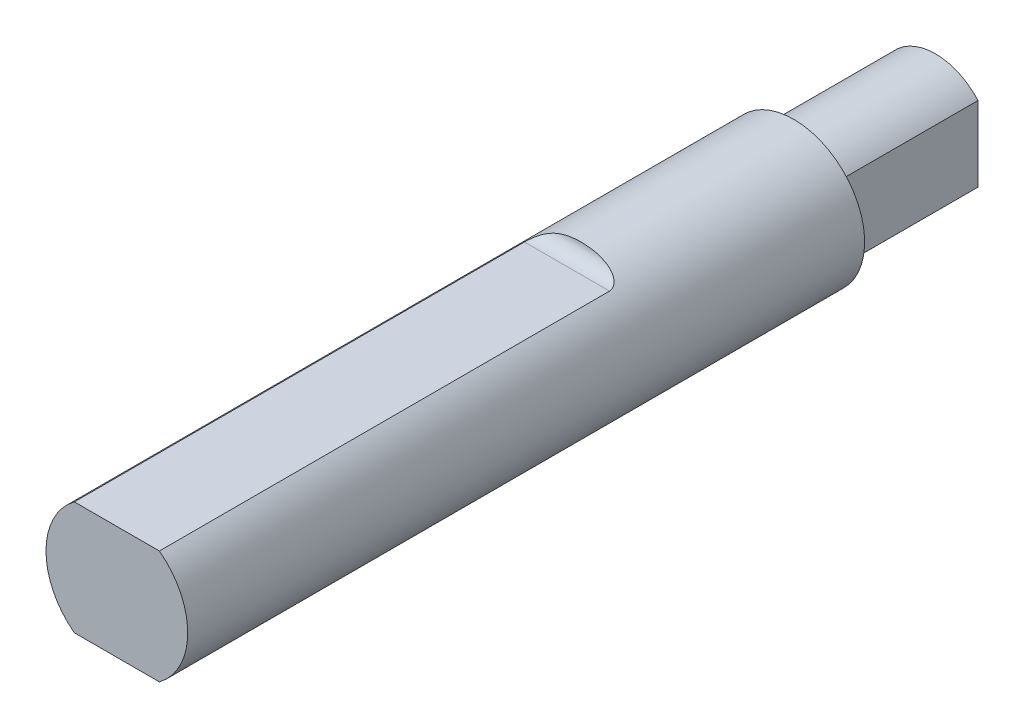
from build123d import *

# Parameters (mm, degrees)
SKETCH1_R               = 2.5
BOSS_EXTRUDE1_DEPTH     = 28.879
SKETCH2_R               = 2.5
CUT_EXTRUDE1_DEPTH      = 5
CUT_EXTRUDE2_DEPTH      = 15.879
CUT_EXTRUDE3_DEPTH      = 3.5
CUT_EXTRUDE3_DEPTH_BACK = 3.5


with BuildPart() as part:
    # Sketch1 → Boss-Extrude1 (new body)
    with BuildSketch(Plane.XY):
        Circle(SKETCH1_R)
    extrude(amount=BOSS_EXTRUDE1_DEPTH)

    # Sketch2 → Cut-Extrude1 (cut)
    with BuildSketch(Plane(origin=(0, 0, 0), x_dir=(-1, 0, 0), z_dir=(0, 0, -1))):
        Circle(SKETCH2_R)
        with BuildLine():
            Line((-1.5, 1.322875656), (-1.5, -1.322875656))
            ThreePointArc((-1.5, -1.322875656), (0, -2), (1.5, -1.322875656))
            Line((1.5, -1.322875656), (1.5, 1.322875656))
            ThreePointArc((1.5, 1.322875656), (0, 2), (-1.5, 1.322875656))
        make_face(mode=Mode.SUBTRACT)
    extrude(amount=-CUT_EXTRUDE1_DEPTH, mode=Mode.SUBTRACT)

    # Sketch3 → Cut-Extrude2 (cut)
    with BuildSketch(Plane.XY.offset(28.879)):
        with BuildLine():
            Line((-1.5, 2), (1.5, 2))
            ThreePointArc((1.5, 2), (0, 2.5), (-1.5, 2))
        make_face()
        with BuildLine():
            Line((-1.5, -2), (1.5, -2))
            ThreePointArc((1.5, -2), (0, -2.5), (-1.5, -2))
        make_face()
    extrude(amount=-CUT_EXTRUDE2_DEPTH, mode=Mode.SUBTRACT)

    # Sketch4 → Cut-Extrude3 (cut, two sides)
    with BuildSketch(Plane(origin=(0, 0, 0), x_dir=(0, 0, -1), z_dir=(1, 0, 0))) as cut_extrude3_sk:
        with BuildLine():
            Line((-13, 2.5), (-13, 2))
            ThreePointArc((-13, 2), (-12.646446609, 2.146446609), (-12.5, 2.5))
            Line((-12.5, 2.5), (-13, 2.5))
        make_face()
        with BuildLine():
            Line((-13, -2.5), (-13, -2))
            ThreePointArc((-13, -2), (-12.646446609, -2.146446609), (-12.5, -2.5))
            Line((-12.5, -2.5), (-13, -2.5))
        make_face()
    extrude(amount=CUT_EXTRUDE3_DEPTH, mode=Mode.SUBTRACT)
    extrude(cut_extrude3_sk.sketch, amount=-CUT_EXTRUDE3_DEPTH_BACK, mode=Mode.SUBTRACT)


solid = part.part
